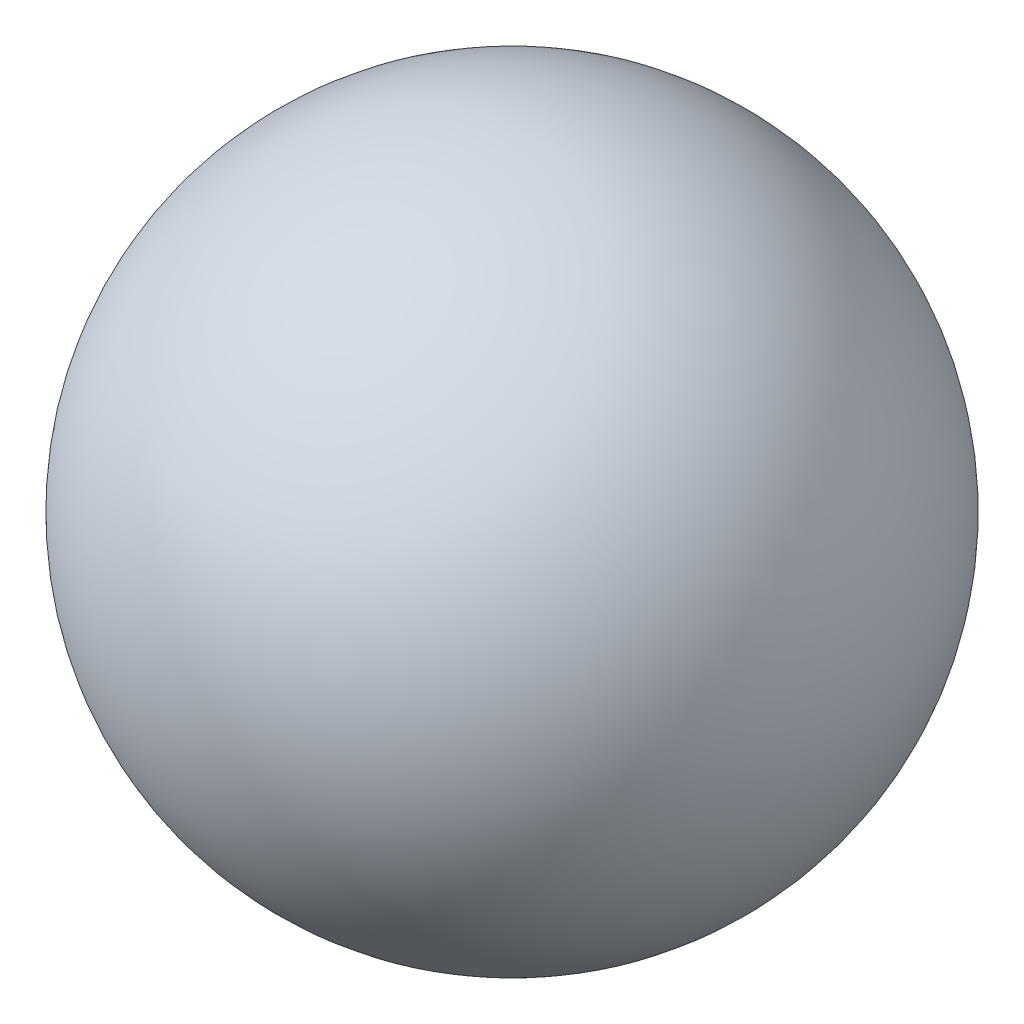
from build123d import *


with BuildPart() as part:
    # Sketch1 → Revolve1 (revolve)
    with BuildSketch(Plane(origin=(0, 0, 0), x_dir=(0, 0, -1), z_dir=(1, 0, 0))):
        with BuildLine():
            Line((0, -165.1), (0, 165.1))
            ThreePointArc((0, 165.1), (165.1, 0), (0, -165.1))
        make_face()
    revolve(axis=Axis((0, -165.1, 0), (0, 1, 0)))


solid = part.part
